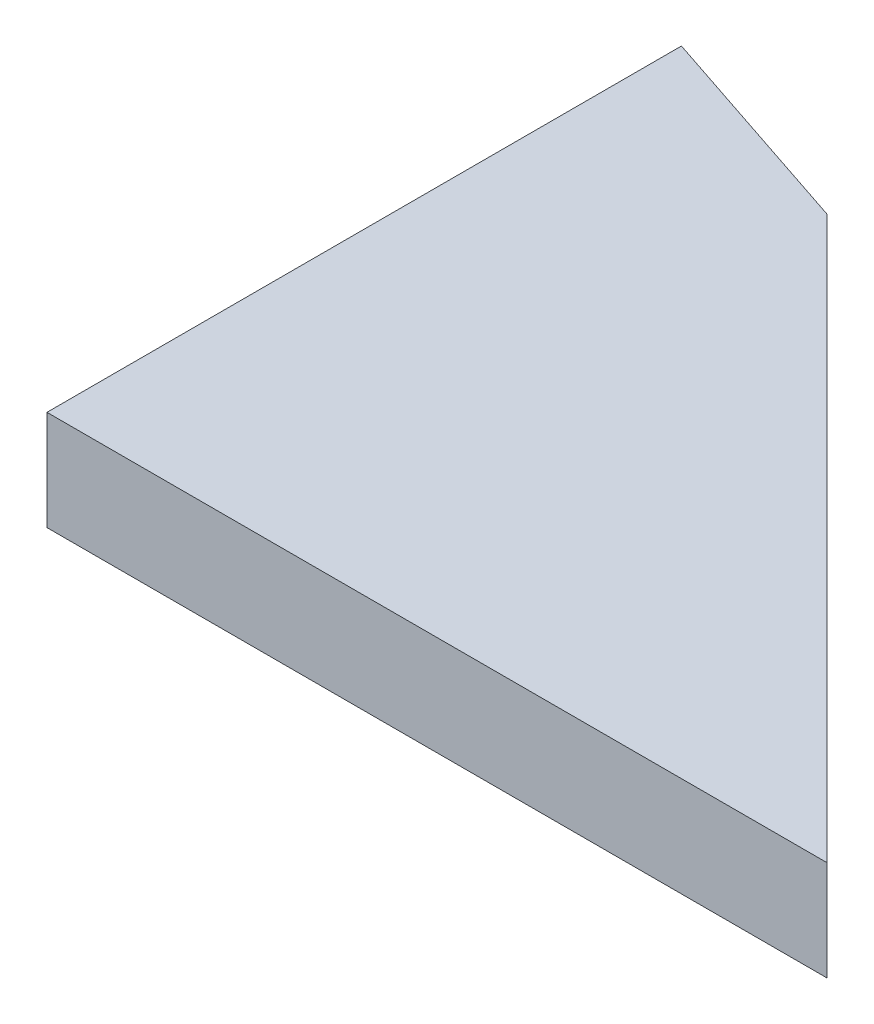
from build123d import *

# Parameters (mm, degrees)
EXTRUDE_D_DEPTH = 6.4


with BuildPart() as part:
    # puzzle plan_6 → Extrude D (new body)
    with BuildSketch(Plane(origin=(0, 0, 0), x_dir=(1, 0, 0), z_dir=(0, 1, 0))):
        Polygon((64, 36), (50, 40.666666667), (50, 0), (100, 0), align=None)
    extrude(amount=EXTRUDE_D_DEPTH)


solid = part.part
